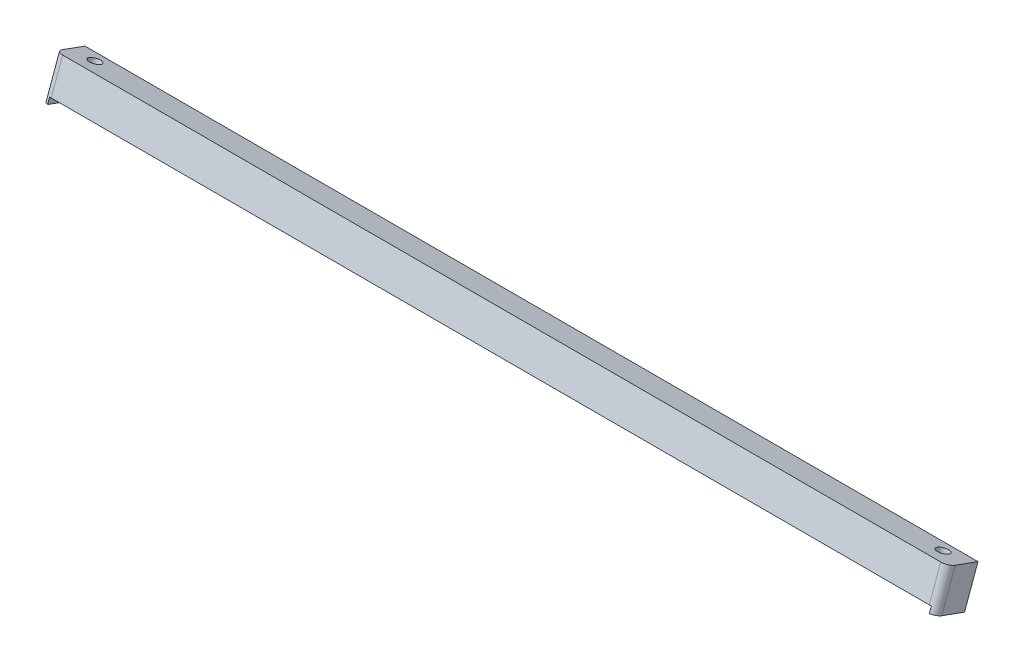
from build123d import *

# Parameters (mm, degrees)
BOSS_EXTRUDE1_DEPTH = 239
SKETCH2_R           = 1.599999999999998
SKETCH2_R_2         = 1.5999999999999908
CUT_EXTRUDE1_DEPTH  = 240.44586691023747
BOSS_EXTRUDE2_DEPTH = 1.6
FILLET1_R           = 2
SKETCH4_W           = 302.77939153503445
SKETCH4_H           = 48.73306397089993
CUT_EXTRUDE2_DEPTH  = 0.55


with BuildPart() as part:
    # Sketch1 → Boss-Extrude1 (new body)
    with BuildSketch(Plane(origin=(0, 0, 0), x_dir=(0, 0, -1), z_dir=(1, 0, 0))):
        Polygon((2.5431313581277277, 8.378511762801937), (-0.1315705594718698, 1.029828640425271), (-8.118957836152065, 3.936999858693529), (-4.86976647455813, 12.864079756159628), (3.117620802122064, 9.95690853789137), align=None)
    extrude(amount=BOSS_EXTRUDE1_DEPTH)

    # Sketch2 → Cut-Extrude1 (cut, through all)
    with BuildSketch(Plane(origin=(0, 9.794155508645982, -3.5647810749215956), x_dir=(1, 0, 0), z_dir=(0, 0.9396926207859053, -0.3420201433256773))):
        with Locations(Location((5.999999999999991, -4.047641310446752, 0), (0, 0, 270))):
            Circle(SKETCH2_R)
        with Locations(Location((232.99999999999997, -4.047641310446725, 0), (0, 0, 270))):
            Circle(SKETCH2_R_2)
    extrude(amount=-CUT_EXTRUDE1_DEPTH, mode=Mode.SUBTRACT)

    # Sketch3 → Boss-Extrude2 (add)
    with BuildSketch(Plane(origin=(0, 0.8670756111798825, -0.31558971332766134), x_dir=(1, 0, 0), z_dir=(0, 0.9396926207859052, -0.34202014332567726))):
        Polygon((0, -0.47585802304752833), (1.5, -0.47585802304752783), (1.5000000000000013, -8.975858023047525), (0, -8.975858023047529), align=None)
        Polygon((239, -0.47585802304752833), (237.5, -0.475858023047528), (237.5, -8.975858023047525), (239, -8.975858023047529), align=None)
    extrude(amount=-BOSS_EXTRUDE2_DEPTH)

    # Fillet1
    fillet1_edges = [part.edges().sort_by_distance(p)[0] for p in [
        (239, 7.6487857107978545, 6.76797827001564),
        (0, 7.648785710797854, 6.76797827001564),
    ]]
    fillet(fillet1_edges, radius=FILLET1_R)

    # Sketch4 → Cut-Extrude2 (cut)
    with BuildSketch(Plane(origin=(0, 9.794155508645986, -3.5647810749215965), x_dir=(1, 0, 0), z_dir=(0, 0.9396926207859053, -0.34202014332567743))):
        with Locations((120.43717430713222, 0.7530071571181338)):
            Rectangle(SKETCH4_W, SKETCH4_H)
    extrude(amount=-CUT_EXTRUDE2_DEPTH, mode=Mode.SUBTRACT)


solid = part.part
